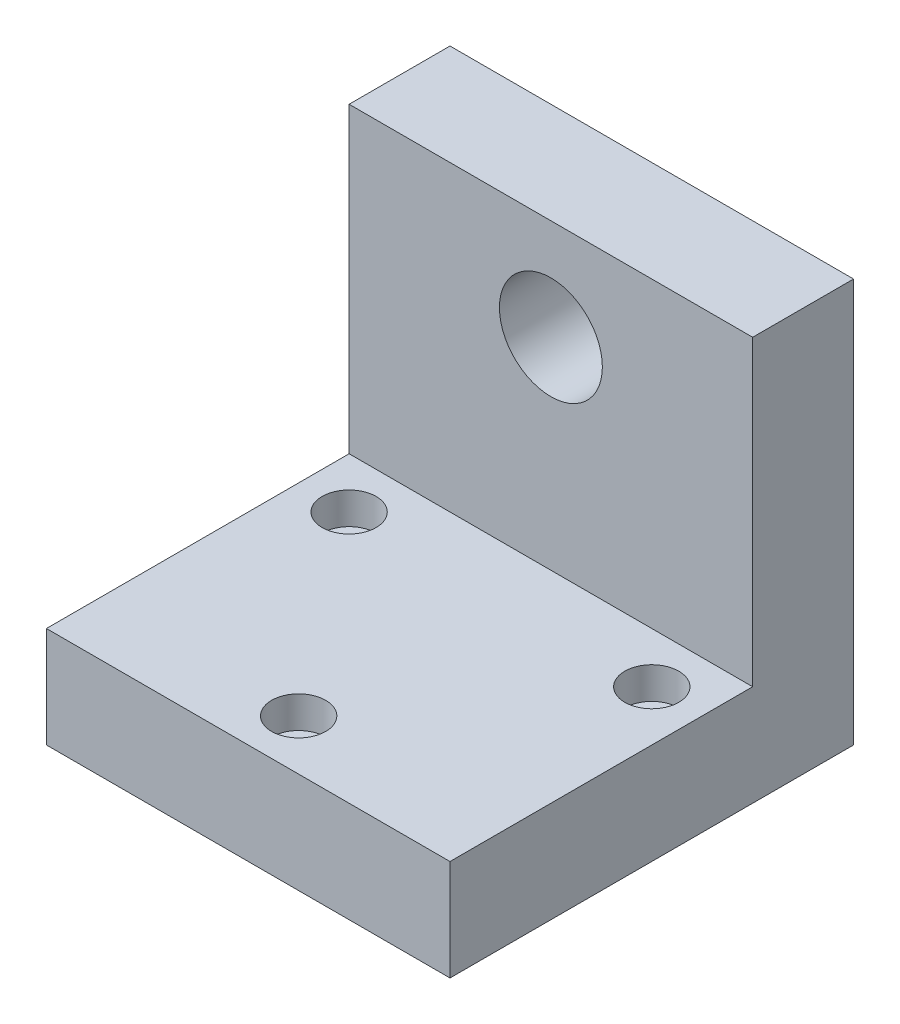
from build123d import *

# Parameters (mm, degrees)
SKETCH1_W               = 25.4
SKETCH1_H               = 25.4
BOSS_EXTRUDE1_DEPTH     = 3.175
SKETCH2_W               = 25.4
SKETCH2_H               = 6.35
BOSS_EXTRUDE2_DEPTH     = 19.05
SKETCH4_R               = 1.127000032
CUT_EXTRUDE2_DEPTH      = 7.35
SKETCH9_R               = 1.700000029
CUT_EXTRUDE4_DEPTH      = 2.000000064
SKETCH3_R               = 3.2385
CUT_EXTRUDE1_DEPTH      = 20.05
CUT_EXTRUDE1_DEPTH_BACK = 7.35


with BuildPart() as part:
    # Sketch1 → Boss-Extrude1 (new body, symmetric)
    with BuildSketch(Plane.XY):
        with Locations((12.7, 12.7)):
            Rectangle(SKETCH1_W, SKETCH1_H)
    extrude(amount=BOSS_EXTRUDE1_DEPTH, both=True)

    # Sketch2 → Boss-Extrude2 (add)
    with BuildSketch(Plane.XY.offset(3.175)):
        with Locations((12.7, 3.175)):
            Rectangle(SKETCH2_W, SKETCH2_H)
    extrude(amount=BOSS_EXTRUDE2_DEPTH)

    # Sketch4 → Cut-Extrude2 (cut, through all)
    with BuildSketch(Plane(origin=(0, 6.35, 0), x_dir=(1, 0, 0), z_dir=(0, 1, 0))):
        with Locations((3.175, -6.35)):
            Circle(SKETCH4_R)
        with Locations((22.225, -6.35)):
            Circle(SKETCH4_R)
        with Locations((12.7, -19.05)):
            Circle(SKETCH4_R)
    extrude(amount=-CUT_EXTRUDE2_DEPTH, mode=Mode.SUBTRACT)

    # Sketch9 → Cut-Extrude4 (cut)
    with BuildSketch(Plane(origin=(0, 6.35, 0), x_dir=(1, 0, 0), z_dir=(0, 1, 0))):
        with Locations((3.175, -6.35)):
            Circle(SKETCH9_R)
        with Locations((22.225, -6.35)):
            Circle(SKETCH9_R)
        with Locations((12.7, -19.05)):
            Circle(SKETCH9_R)
    extrude(amount=-CUT_EXTRUDE4_DEPTH, mode=Mode.SUBTRACT)

    # Sketch3 → Cut-Extrude1 (cut, two sides)
    with BuildSketch(Plane.XY.offset(3.175)) as cut_extrude1_sk:
        with Locations((12.7, 19.05)):
            Circle(SKETCH3_R)
    extrude(amount=CUT_EXTRUDE1_DEPTH, mode=Mode.SUBTRACT)
    extrude(cut_extrude1_sk.sketch, amount=-CUT_EXTRUDE1_DEPTH_BACK, mode=Mode.SUBTRACT)


solid = part.part
